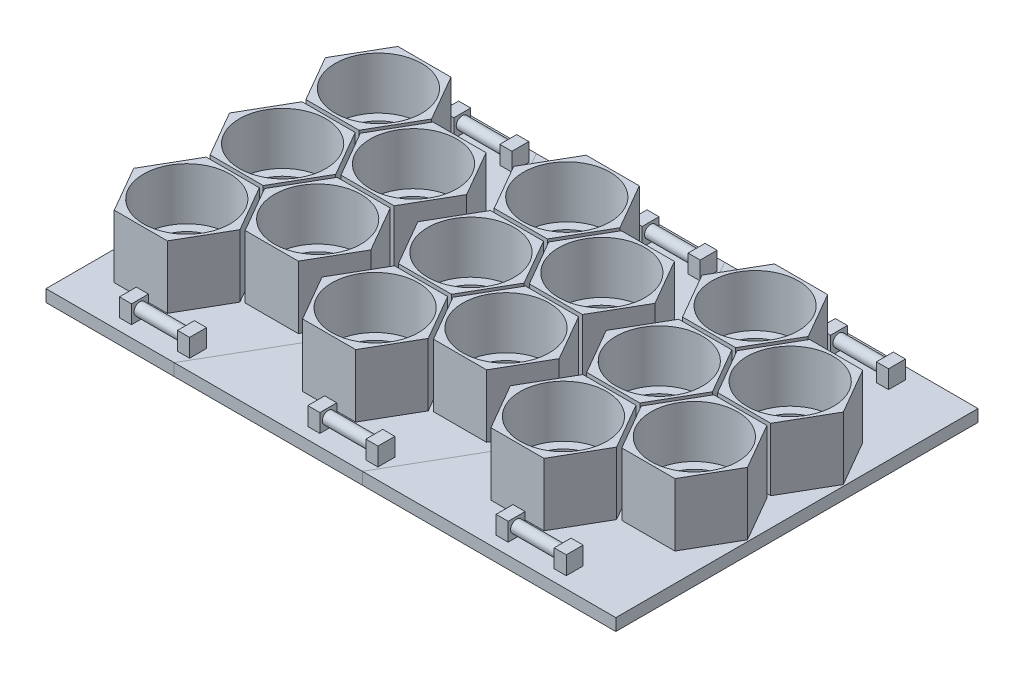
from build123d import *

# Parameters (mm, degrees)
SKETCH1_W                 = 236
SKETCH1_H                 = 75
BOSS_EXTRUDE1_DEPTH       = 2.5
BOSS_EXTRUDE2_DEPTH       = 26
SKETCH4_R                 = 13.97
CUT_EXTRUDE1_DEPTH        = 25.4
SKETCH4_4_R               = 17.907
CUT_EXTRUDE2_DEPTH        = 21.55444
LPATTERN1_COUNT           = 3
LPATTERN1_PITCH           = 78
SKETCH10_W                = 5
SKETCH10_H                = 7
BOSS_EXTRUDE7_DEPTH       = 7.5
SKETCH12_R                = 2.5
BOSS_EXTRUDE8_DEPTH       = 19.05
LPATTERN2_COUNT           = 3
LPATTERN2_PITCH           = 78
LPATTERN2_COPY_1_SKETCH_W = 5
LPATTERN2_COPY_1_SKETCH_H = 7
LPATTERN2_COPY_1_DEPTH    = 7.5
LPATTERN2_COPY_2_SKETCH_W = 5
LPATTERN2_COPY_2_SKETCH_H = 7
LPATTERN2_COPY_2_DEPTH    = 7.5
LPATTERN2_COPY_3_SKETCH_R = 2.5
LPATTERN2_COPY_3_DEPTH    = 19.05
LPATTERN2_COPY_4_SKETCH_R = 2.5
LPATTERN2_COPY_4_DEPTH    = 19.05
SPLIT1_SURFACE_1_1_BACK   = 282.349
SPLIT1_SURFACE_1_1_DEPTH  = 564.698
SPLIT1_SURFACE_1_2_BACK   = 282.349
SPLIT1_SURFACE_1_2_DEPTH  = 564.698
SPLIT1_SURFACE_2_3_BACK   = 282.349
SPLIT1_SURFACE_2_3_DEPTH  = 564.698
SPLIT1_SURFACE_2_4_BACK   = 282.349
SPLIT1_SURFACE_2_4_DEPTH  = 564.698


with BuildPart() as part:
    # Sketch1 → Boss-Extrude1 (new, symmetric)
    with BuildSketch(Plane(origin=(0, 0, 0), x_dir=(1, 0, 0), z_dir=(0, 1, 0))):
        with Locations((0, -37.5)):
            Rectangle(SKETCH1_W, SKETCH1_H)
        with Locations((0, 37.5)):
            Rectangle(SKETCH1_W, SKETCH1_H)
    extrude(amount=BOSS_EXTRUDE1_DEPTH, both=True)

    # Sketch3 → Boss-Extrude2 (add)
    with BuildSketch(Plane(origin=(0, 2.5, 0), x_dir=(1, 0, 0), z_dir=(0, 1, 0))):
        Polygon((-84.001477372, 20.6375), (-73.002954744, 39.6875), (-84.001477372, 58.7375), (-105.998522628, 58.7375), (-116.997045256, 39.6875), (-105.998522628, 20.6375), align=None)
        Polygon((-38.632571531, 19.84375), (-49.631094159, 0.79375), (-71.628139415, 0.79375), (-82.626662043, 19.84375), (-71.628139415, 38.89375), (-49.631094159, 38.89375), align=None)
        Polygon((-84.001477372, -19.05), (-73.002954744, 0), (-84.001477372, 19.05), (-105.998522628, 19.05), (-116.997045256, 0), (-105.998522628, -19.05), align=None)
        Polygon((-105.998522628, -58.7375), (-84.001477372, -58.7375), (-73.002954744, -39.6875), (-84.001477372, -20.6375), (-105.998522628, -20.6375), (-116.997045256, -39.6875), align=None)
        Polygon((-71.628139415, -38.89375), (-49.631094159, -38.89375), (-38.632571531, -19.84375), (-49.631094159, -0.79375), (-71.628139415, -0.79375), (-82.626662043, -19.84375), align=None)
    boss_extrude2 = extrude(amount=BOSS_EXTRUDE2_DEPTH)

    # Sketch4 → Cut-Extrude1 (cut)
    with BuildSketch(Plane(origin=(0, 28.5, 0), x_dir=(1, 0, 0), z_dir=(0, 1, 0))):
        with Locations(Location((-95, 0, 0), (0, 0, 270))):
            Circle(SKETCH4_R)
        with Locations(Location((-95, -39.6875, 0), (0, 0, 270))):
            Circle(SKETCH4_R)
        with Locations(Location((-95, 39.6875, 0), (0, 0, 90))):
            Circle(SKETCH4_R)
        with Locations(Location((-60.629616787, 19.84375, 0), (0, 0, 270))):
            Circle(SKETCH4_R)
        with Locations(Location((-60.629616787, -19.84375, 0), (0, 0, 90))):
            Circle(SKETCH4_R)
    cut_extrude1 = extrude(amount=-CUT_EXTRUDE1_DEPTH, mode=Mode.SUBTRACT)

    # Sketch4_4 → Cut-Extrude2 (cut)
    with BuildSketch(Plane(origin=(0, 28.5, 0), x_dir=(1, 0, 0), z_dir=(0, 1, 0))):
        with Locations(Location((-95, 0, 0), (0, 0, 270))):
            Circle(SKETCH4_4_R)
        with Locations(Location((-95, -39.6875, 0), (0, 0, 270))):
            Circle(SKETCH4_4_R)
        with Locations(Location((-95, 39.6875, 0), (0, 0, 90))):
            Circle(SKETCH4_4_R)
        with Locations(Location((-60.629616787, 19.84375, 0), (0, 0, 270))):
            Circle(SKETCH4_4_R)
        with Locations(Location((-60.629616787, -19.84375, 0), (0, 0, 90))):
            Circle(SKETCH4_4_R)
    cut_extrude2 = extrude(amount=-CUT_EXTRUDE2_DEPTH, mode=Mode.SUBTRACT)

    # LPattern1: Boss-Extrude2, Cut-Extrude1, Cut-Extrude2 ×3
    with Locations(*[(i * LPATTERN1_PITCH, 0, 0) for i in range(1, LPATTERN1_COUNT)]):
        add(boss_extrude2)
        add(cut_extrude1, mode=Mode.SUBTRACT)
        add(cut_extrude2, mode=Mode.SUBTRACT)

    # Sketch10 → Boss-Extrude7 (add)
    with BuildSketch(Plane(origin=(0, 2.5, 0), x_dir=(1, 0, 0), z_dir=(0, 1, 0))):
        with Locations((-89.839808394, -66.7375)):
            Rectangle(SKETCH10_W, SKETCH10_H)
        with Locations((-65.789808394, -66.7375)):
            Rectangle(SKETCH10_W, SKETCH10_H)
    boss_extrude7 = extrude(amount=BOSS_EXTRUDE7_DEPTH)

    # Sketch12 → Boss-Extrude8 (add)
    with BuildSketch(Plane(origin=(-87.339808394, 0, 0), x_dir=(0, 0, -1), z_dir=(1, 0, 0))):
        with Locations(Location((-66.7375, 6.5, 0), (0, 0, 180))):
            Circle(SKETCH12_R)
    boss_extrude8 = extrude(amount=BOSS_EXTRUDE8_DEPTH)

    # Mirror1: Boss-Extrude7, Boss-Extrude8 across plane
    add(boss_extrude7.mirror(Plane.XY))
    add(boss_extrude8.mirror(Plane.XY))

    # LPattern2: Boss-Extrude7, Boss-Extrude8 ×3
    with Locations(*[(i * LPATTERN2_PITCH, 0, 0) for i in range(1, LPATTERN2_COUNT)]):
        add(boss_extrude7)
        add(boss_extrude8)

    # LPattern2 copy 1 sketch → LPattern2 copy 1 (add)
    with BuildSketch(Plane(origin=(78, 2.5, 0), x_dir=(1, 0, 0), z_dir=(0, 1, 0))):
        with Locations((-89.839808394, 66.7375)):
            Rectangle(LPATTERN2_COPY_1_SKETCH_W, LPATTERN2_COPY_1_SKETCH_H)
        with Locations((-65.789808394, 66.7375)):
            Rectangle(LPATTERN2_COPY_1_SKETCH_W, LPATTERN2_COPY_1_SKETCH_H)
    extrude(amount=LPATTERN2_COPY_1_DEPTH)

    # LPattern2 copy 2 sketch → LPattern2 copy 2 (add)
    with BuildSketch(Plane(origin=(156, 2.5, 0), x_dir=(1, 0, 0), z_dir=(0, 1, 0))):
        with Locations((-89.839808394, 66.7375)):
            Rectangle(LPATTERN2_COPY_2_SKETCH_W, LPATTERN2_COPY_2_SKETCH_H)
        with Locations((-65.789808394, 66.7375)):
            Rectangle(LPATTERN2_COPY_2_SKETCH_W, LPATTERN2_COPY_2_SKETCH_H)
    extrude(amount=LPATTERN2_COPY_2_DEPTH)

    # LPattern2 copy 3 sketch → LPattern2 copy 3 (add)
    with BuildSketch(Plane(origin=(-9.339808394, 0, 0), x_dir=(0, 0, 1), z_dir=(1, 0, 0))):
        with Locations((-66.7375, -6.5)):
            Circle(LPATTERN2_COPY_3_SKETCH_R)
    extrude(amount=LPATTERN2_COPY_3_DEPTH)

    # LPattern2 copy 4 sketch → LPattern2 copy 4 (add)
    with BuildSketch(Plane(origin=(68.660191606, 0, 0), x_dir=(0, 0, 1), z_dir=(1, 0, 0))):
        with Locations((-66.7375, -6.5)):
            Circle(LPATTERN2_COPY_4_SKETCH_R)
    extrude(amount=LPATTERN2_COPY_4_DEPTH)


with BuildPart() as body_2:
    # Split1: the piece behind the surface
    add(part.part)
    # Split1 surface 1: a surface, the sketch's curves swept straight by 564.698 mm
    with BuildLine(Plane(origin=(0, 2.5, 0), x_dir=(1, 0, 0), z_dir=(0, 1, 0)).offset(-SPLIT1_SURFACE_1_1_BACK), mode=Mode.PRIVATE) as split1_surface_1_1_path:
        Line((-64.930886977, -75), (-35.53844397, -24.090795355))
        Line((-35.53844397, -24.090795355), (-33.086411192, -19.84375))
        Line((-33.086411192, -19.84375), (-39.731799052, -8.333600589))
        Line((-39.731799052, -8.333600589), (-44.543205596, 0))
        Line((-44.543205596, 0), (-39.97221259, 7.917192126))
        Line((-39.97221259, 7.917192126), (-33.086411192, 19.84375))
        Line((-33.086411192, 19.84375), (-39.97221259, 31.770307874))
        Line((-39.97221259, 31.770307874), (-64.930886977, 75))
    split1_surface_1_1 = Shell.extrude(split1_surface_1_1_path.wire(), (0 * SPLIT1_SURFACE_1_1_DEPTH, 1 * SPLIT1_SURFACE_1_1_DEPTH, 0 * SPLIT1_SURFACE_1_1_DEPTH))
    split(bisect_by=split1_surface_1_1, keep=Keep.BOTTOM)


with BuildPart() as part_1:
    add(part.part)

    # Split1: split by a surface, the side it looks to stays
    # Split1 surface 1: a surface, the sketch's curves swept straight by 564.698 mm
    with BuildLine(Plane(origin=(0, 2.5, 0), x_dir=(1, 0, 0), z_dir=(0, 1, 0)).offset(-SPLIT1_SURFACE_1_2_BACK), mode=Mode.PRIVATE) as split1_surface_1_2_path:
        Line((-64.930886977, -75), (-35.53844397, -24.090795355))
        Line((-35.53844397, -24.090795355), (-33.086411192, -19.84375))
        Line((-33.086411192, -19.84375), (-39.731799052, -8.333600589))
        Line((-39.731799052, -8.333600589), (-44.543205596, 0))
        Line((-44.543205596, 0), (-39.97221259, 7.917192126))
        Line((-39.97221259, 7.917192126), (-33.086411192, 19.84375))
        Line((-33.086411192, 19.84375), (-39.97221259, 31.770307874))
        Line((-39.97221259, 31.770307874), (-64.930886977, 75))
    split1_surface_1_2 = Shell.extrude(split1_surface_1_2_path.wire(), (0 * SPLIT1_SURFACE_1_2_DEPTH, 1 * SPLIT1_SURFACE_1_2_DEPTH, 0 * SPLIT1_SURFACE_1_2_DEPTH))
    split(bisect_by=split1_surface_1_2, keep=Keep.TOP)


with BuildPart() as body_3:
    # Split1 2 body 2: the piece behind the surface
    add(body_2.part)
    # Split1 surface 2: a surface, the sketch's curves swept straight by 564.698 mm
    with BuildLine(Plane(origin=(0, 2.5, 0), x_dir=(1, 0, 0), z_dir=(0, 1, 0)).offset(-SPLIT1_SURFACE_2_3_BACK), mode=Mode.PRIVATE) as split1_surface_2_3_path:
        Line((13.069113023, 75), (41.969616323, 24.942859921))
        Line((41.969616323, 24.942859921), (44.913588808, 19.84375))
        Line((44.913588808, 19.84375), (38.02778741, 7.917192126))
        Line((38.02778741, 7.917192126), (33.456794404, 0))
        Line((33.456794404, 0), (43.527048724, -17.442192126))
        Line((43.527048724, -17.442192126), (44.913588808, -19.84375))
        Line((44.913588808, -19.84375), (38.02778741, -31.770307874))
        Line((38.02778741, -31.770307874), (13.069113023, -75))
    split1_surface_2_3 = Shell.extrude(split1_surface_2_3_path.wire(), (0 * SPLIT1_SURFACE_2_3_DEPTH, 1 * SPLIT1_SURFACE_2_3_DEPTH, 0 * SPLIT1_SURFACE_2_3_DEPTH))
    split(bisect_by=split1_surface_2_3, keep=Keep.BOTTOM)


with BuildPart() as body_2_1:
    add(body_2.part)

    # Split1 2 body 2: split by a surface, the side it looks to stays
    # Split1 surface 2: a surface, the sketch's curves swept straight by 564.698 mm
    with BuildLine(Plane(origin=(0, 2.5, 0), x_dir=(1, 0, 0), z_dir=(0, 1, 0)).offset(-SPLIT1_SURFACE_2_4_BACK), mode=Mode.PRIVATE) as split1_surface_2_4_path:
        Line((13.069113023, 75), (41.969616323, 24.942859921))
        Line((41.969616323, 24.942859921), (44.913588808, 19.84375))
        Line((44.913588808, 19.84375), (38.02778741, 7.917192126))
        Line((38.02778741, 7.917192126), (33.456794404, 0))
        Line((33.456794404, 0), (43.527048724, -17.442192126))
        Line((43.527048724, -17.442192126), (44.913588808, -19.84375))
        Line((44.913588808, -19.84375), (38.02778741, -31.770307874))
        Line((38.02778741, -31.770307874), (13.069113023, -75))
    split1_surface_2_4 = Shell.extrude(split1_surface_2_4_path.wire(), (0 * SPLIT1_SURFACE_2_4_DEPTH, 1 * SPLIT1_SURFACE_2_4_DEPTH, 0 * SPLIT1_SURFACE_2_4_DEPTH))
    split(bisect_by=split1_surface_2_4, keep=Keep.TOP)


solid = Compound([part_1.part, body_3.part, body_2_1.part])
